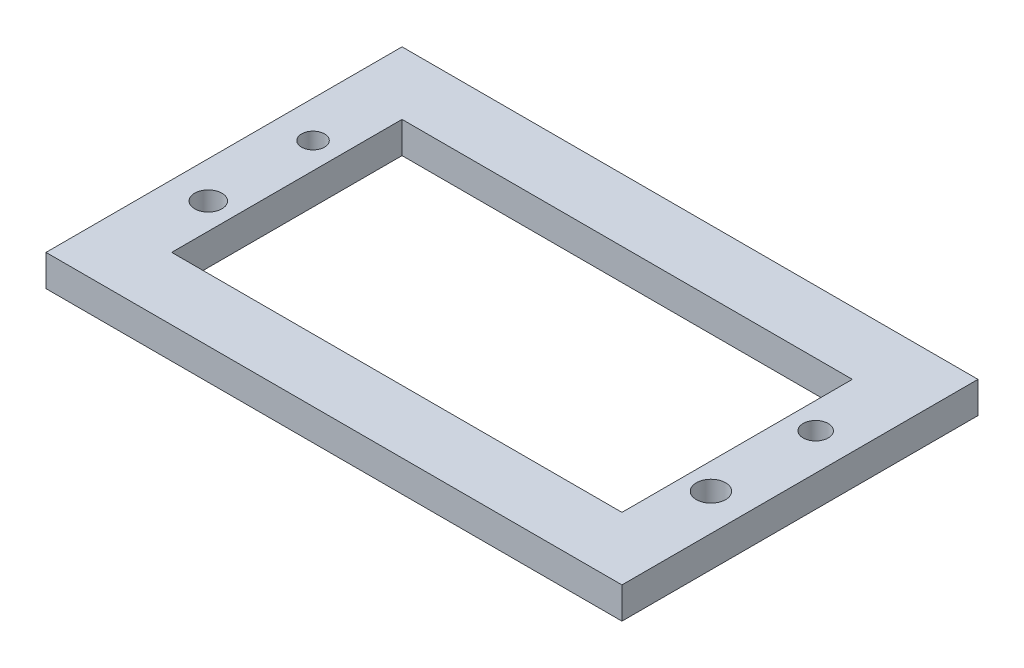
from build123d import *

# Parameters (mm, degrees)
SKETCH1_W           = 55
SKETCH1_H           = 34
SKETCH1_R           = 1.1
SKETCH1_R_2         = 1.3
SKETCH1_R_3         = 1.2
SKETCH1_R_4         = 1.4
SKETCH1_W_2         = 43
SKETCH1_H_2         = 22
BOSS_EXTRUDE1_DEPTH = 3


with BuildPart() as part:
    # Sketch1 → Boss-Extrude1 (new body)
    with BuildSketch(Plane(origin=(0, 0, 0), x_dir=(1, 0, 0), z_dir=(0, 1, 0))):
        Rectangle(SKETCH1_W, SKETCH1_H)
        with Locations((-24, 5)):
            Circle(SKETCH1_R, mode=Mode.SUBTRACT)
        with Locations((-24, -5)):
            Circle(SKETCH1_R_2, mode=Mode.SUBTRACT)
        with Locations((24, 5)):
            Circle(SKETCH1_R_3, mode=Mode.SUBTRACT)
        with Locations((24, -5)):
            Circle(SKETCH1_R_4, mode=Mode.SUBTRACT)
        Rectangle(SKETCH1_W_2, SKETCH1_H_2, mode=Mode.SUBTRACT)
    extrude(amount=BOSS_EXTRUDE1_DEPTH)


solid = part.part
